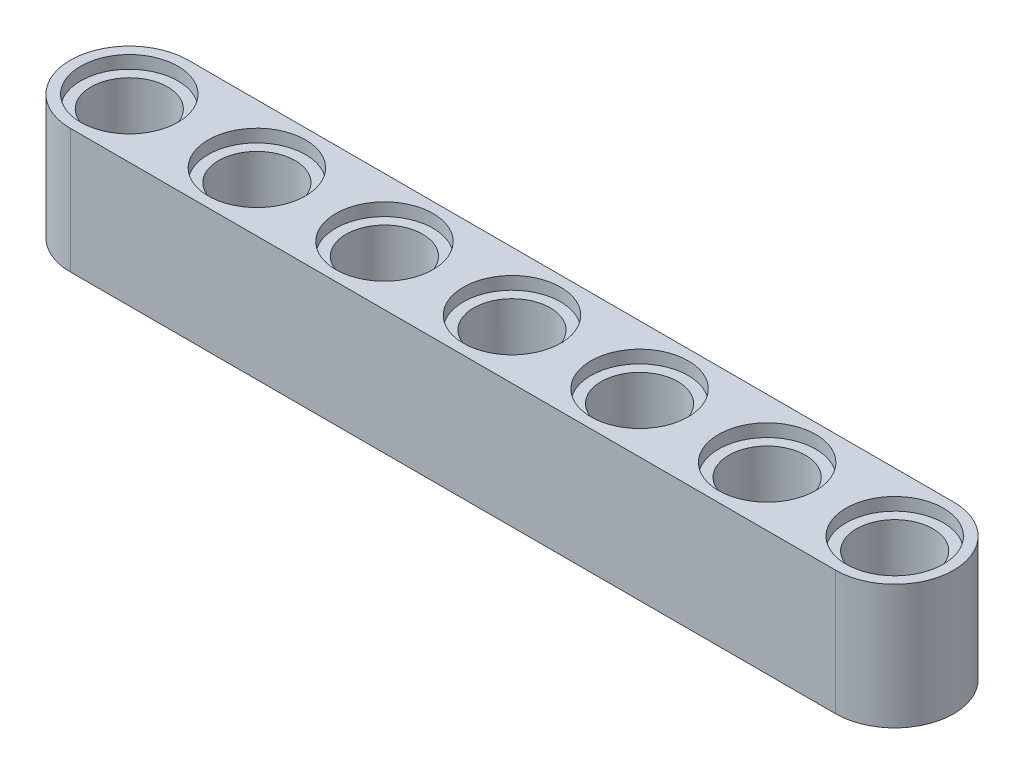
from build123d import *

# Parameters (mm, degrees)
BOSS_EXTRUDE3_DEPTH = 7.8
SKETCH2_R           = 2.4
CUT_EXTRUDE1_DEPTH  = 7.8
SKETCH3_R           = 3.05
CUT_EXTRUDE2_DEPTH  = 0.8
SKETCH4_R           = 3.05
CUT_EXTRUDE3_DEPTH  = 0.8


with BuildPart() as part:
    # Sketch1 → Boss-Extrude3 (new body)
    with BuildSketch(Plane(origin=(0, 0, 0), x_dir=(1, 0, 0), z_dir=(0, 1, 0))):
        with BuildLine():
            Line((-16, -3.7), (32, -3.7))
            ThreePointArc((32, -3.7), (35.7, 0), (32, 3.7))
            Line((32, 3.7), (-16, 3.7))
            ThreePointArc((-16, 3.7), (-19.7, 0), (-16, -3.7))
        make_face()
    extrude(amount=BOSS_EXTRUDE3_DEPTH)

    # Sketch2 → Cut-Extrude1 (cut)
    with BuildSketch(Plane(origin=(0, 7.8, 0), x_dir=(1, 0, 0), z_dir=(0, 1, 0))):
        Circle(SKETCH2_R)
        with Locations((8, 0)):
            Circle(SKETCH2_R)
        with Locations((16, 0)):
            Circle(SKETCH2_R)
        with Locations((-16, 0)):
            Circle(SKETCH2_R)
        with Locations((-8, 0)):
            Circle(SKETCH2_R)
        with Locations((24, 0)):
            Circle(SKETCH2_R)
        with Locations((32, 0)):
            Circle(SKETCH2_R)
    extrude(amount=-CUT_EXTRUDE1_DEPTH, mode=Mode.SUBTRACT)

    # Sketch3 → Cut-Extrude2 (cut)
    with BuildSketch(Plane(origin=(0, 7.8, 0), x_dir=(1, 0, 0), z_dir=(0, 1, 0))):
        Circle(SKETCH3_R)
        with Locations((8, 0)):
            Circle(SKETCH3_R)
        with Locations((16, 0)):
            Circle(SKETCH3_R)
        with Locations((-16, 0)):
            Circle(SKETCH3_R)
        with Locations((-8, 0)):
            Circle(SKETCH3_R)
        with Locations((32, 0)):
            Circle(SKETCH3_R)
        with Locations((24, 0)):
            Circle(SKETCH3_R)
    extrude(amount=-CUT_EXTRUDE2_DEPTH, mode=Mode.SUBTRACT)

    # Sketch4 → Cut-Extrude3 (cut)
    with BuildSketch(Plane.XZ):
        Circle(SKETCH4_R)
        with Locations((8, 0)):
            Circle(SKETCH4_R)
        with Locations((16, 0)):
            Circle(SKETCH4_R)
        with Locations((-16, 0)):
            Circle(SKETCH4_R)
        with Locations((-8, 0)):
            Circle(SKETCH4_R)
        with Locations((32, 0)):
            Circle(SKETCH4_R)
        with Locations((24, 0)):
            Circle(SKETCH4_R)
    extrude(amount=-CUT_EXTRUDE3_DEPTH, mode=Mode.SUBTRACT)


solid = part.part
